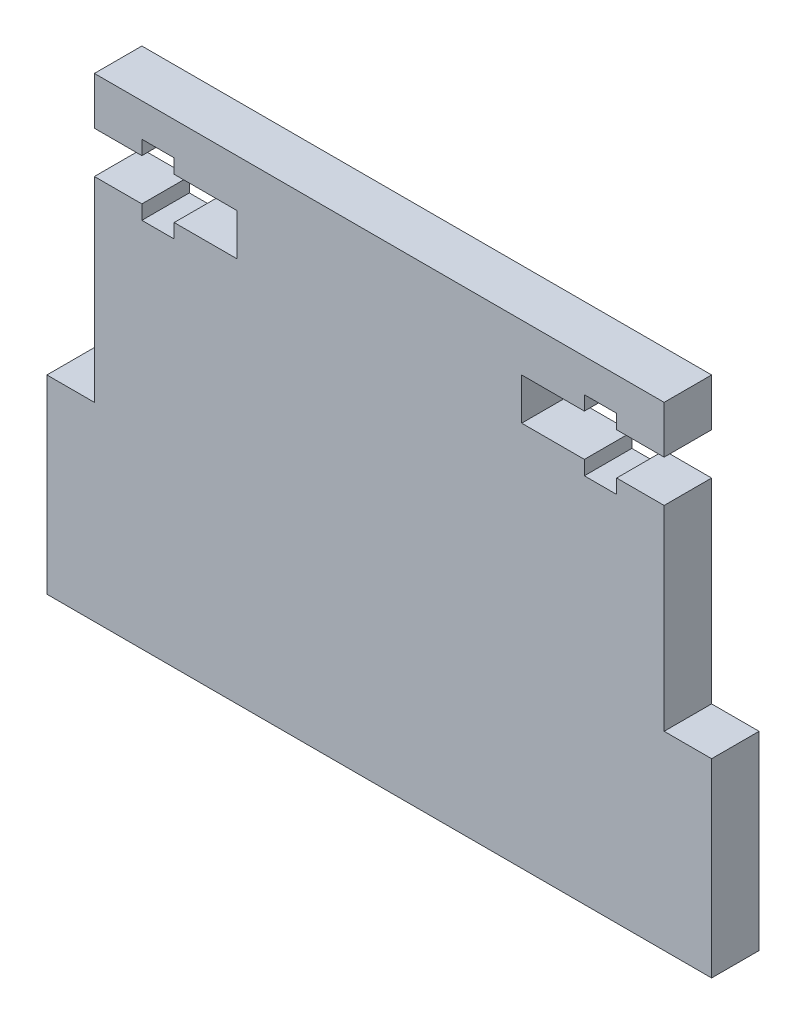
from build123d import *

# Parameters (mm, degrees)
SKETCH1_W           = 60
SKETCH1_H           = 50
BOSS_EXTRUDE1_DEPTH = 5
CUT_EXTRUDE1_DEPTH  = 5
SKETCH6_W           = 5
SKETCH6_H           = 20
BOSS_EXTRUDE2_DEPTH = 5


with BuildPart() as part:
    # Sketch1 → Boss-Extrude1 (new body)
    with BuildSketch(Plane.XY):
        Rectangle(SKETCH1_W, SKETCH1_H)
    extrude(amount=BOSS_EXTRUDE1_DEPTH)

    # Sketch5 → Cut-Extrude1 (cut)
    with BuildSketch(Plane.XY.offset(5)):
        Polygon((-30, 15.6), (-30, 20), (-25, 20), (-25, 21.5), (-21.6, 21.5), (-21.6, 20), (-15, 20), (-15, 15.6), (-21.6, 15.6), (-21.6, 14.1), (-25, 14.1), (-25, 15.6), align=None)
        Polygon((30, 20), (25, 20), (25, 21.5), (21.6, 21.5), (21.6, 20), (15, 20), (15, 15.6), (21.6, 15.6), (21.6, 14.1), (25, 14.1), (25, 15.6), (30, 15.6), align=None)
    extrude(amount=-CUT_EXTRUDE1_DEPTH, mode=Mode.SUBTRACT)

    # Sketch6 → Boss-Extrude2 (add)
    with BuildSketch(Plane(origin=(0, 0, 0), x_dir=(-1, 0, 0), z_dir=(0, 0, -1))):
        with Locations((-32.5, -15)):
            Rectangle(SKETCH6_W, SKETCH6_H)
        with Locations((32.5, -15)):
            Rectangle(SKETCH6_W, SKETCH6_H)
    extrude(amount=-BOSS_EXTRUDE2_DEPTH)


solid = part.part
